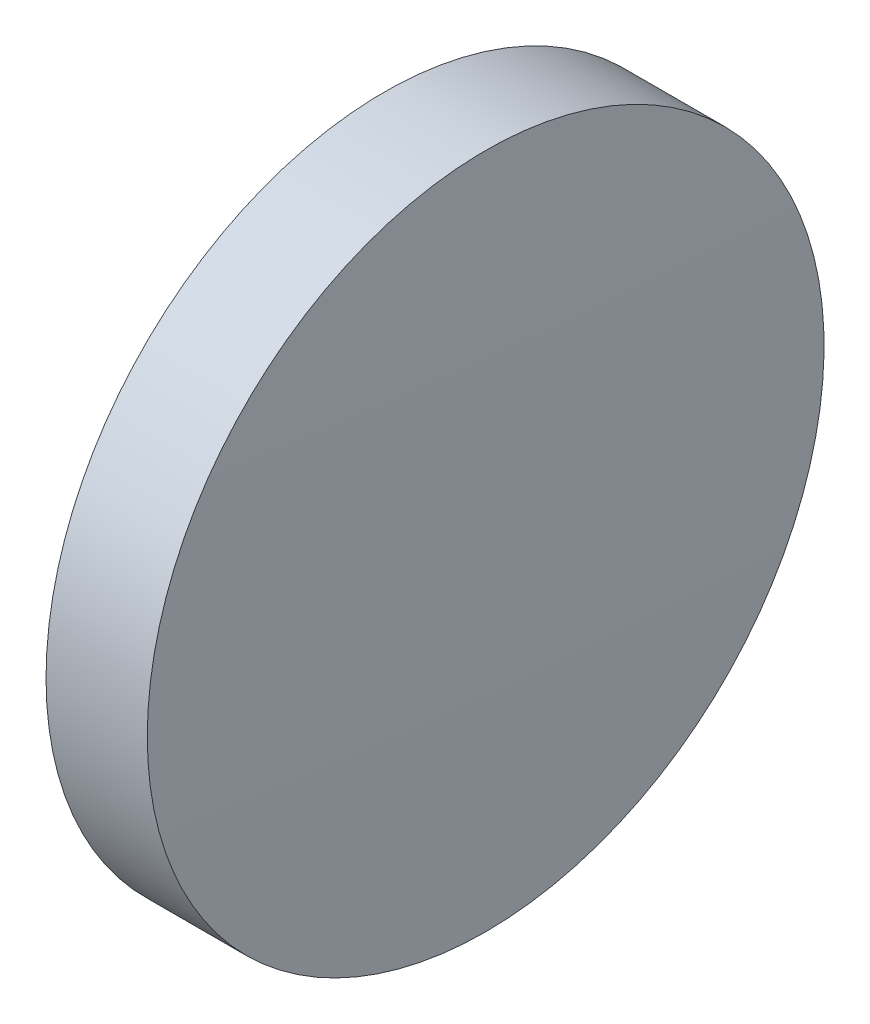
from build123d import *


with BuildPart() as part:
    # 草图1 → 旋转1 (revolve)
    with BuildSketch(Plane.XY, mode=Mode.PRIVATE) as revolve_1_sk:
        with BuildLine():
            Line((115.764555476, 65.233554926), (115.764555476, 77.933554926))
            Line((115.764555476, 77.933554926), (119.564555476, 77.933554926))
            ThreePointArc((119.564555476, 77.933554926), (119.714552377, 71.584342279), (119.764555476, 65.233554926))
            Line((119.764555476, 65.233554926), (115.764555476, 65.233554926))
        make_face()
    revolve(revolve_1_sk.sketch.rotate(Axis((110.165373228, 65.233554926, 0), (1, 0, 0)), 180), axis=Axis((110.165373228, 65.233554926, 0), (1, 0, 0)))  # turned: the seam where the file's is


solid = part.part
